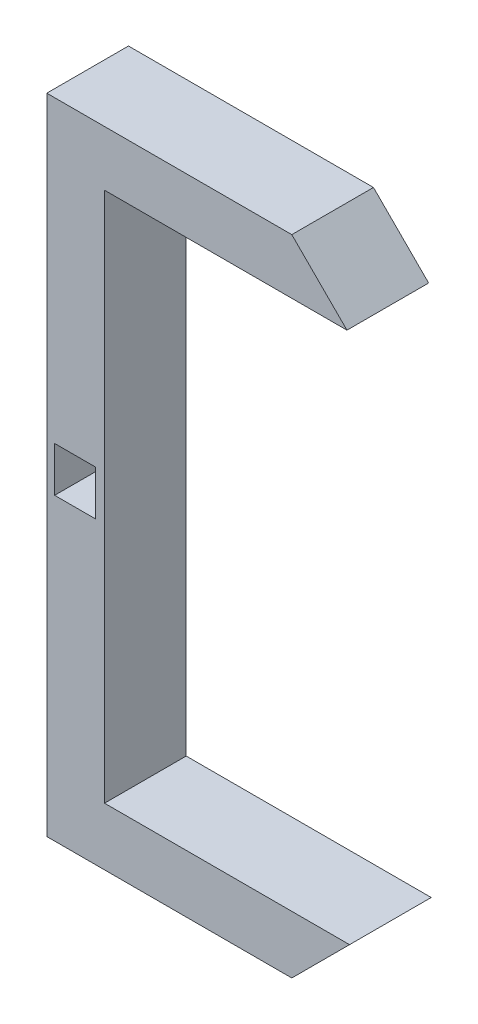
from build123d import *

# Parameters (mm, degrees)
BOSS_EXTRUDE1_DEPTH     = 10
SKETCH2_W               = 5
SKETCH2_H               = 5.5
CUT_EXTRUDE2_DEPTH      = 11
CUT_EXTRUDE2_DEPTH_BACK = 10


with BuildPart() as part:
    # Sketch1 → Boss-Extrude1 (new body)
    with BuildSketch(Plane.XY):
        Polygon((-15.00519424, 49.714572154), (-44.689605678, 49.714572154), (-44.689605678, -15.285427846), (-14.689605678, -15.285427846), (-21.76067349, -22.356495658), (-51.76067349, -22.356495658), (-51.76067349, -18.214360034), (-51.76067349, 56.470051403), (-21.76067349, 56.470051403), align=None)
    extrude(amount=BOSS_EXTRUDE1_DEPTH)

    # Sketch2 → Cut-Extrude2 (cut, two sides)
    with BuildSketch(Plane.XY) as cut_extrude2_sk:
        with Locations((-48.298710813, 17.056777872)):
            Rectangle(SKETCH2_W, SKETCH2_H)
    extrude(amount=CUT_EXTRUDE2_DEPTH, mode=Mode.SUBTRACT)
    extrude(cut_extrude2_sk.sketch, amount=-CUT_EXTRUDE2_DEPTH_BACK, mode=Mode.SUBTRACT)


solid = part.part
